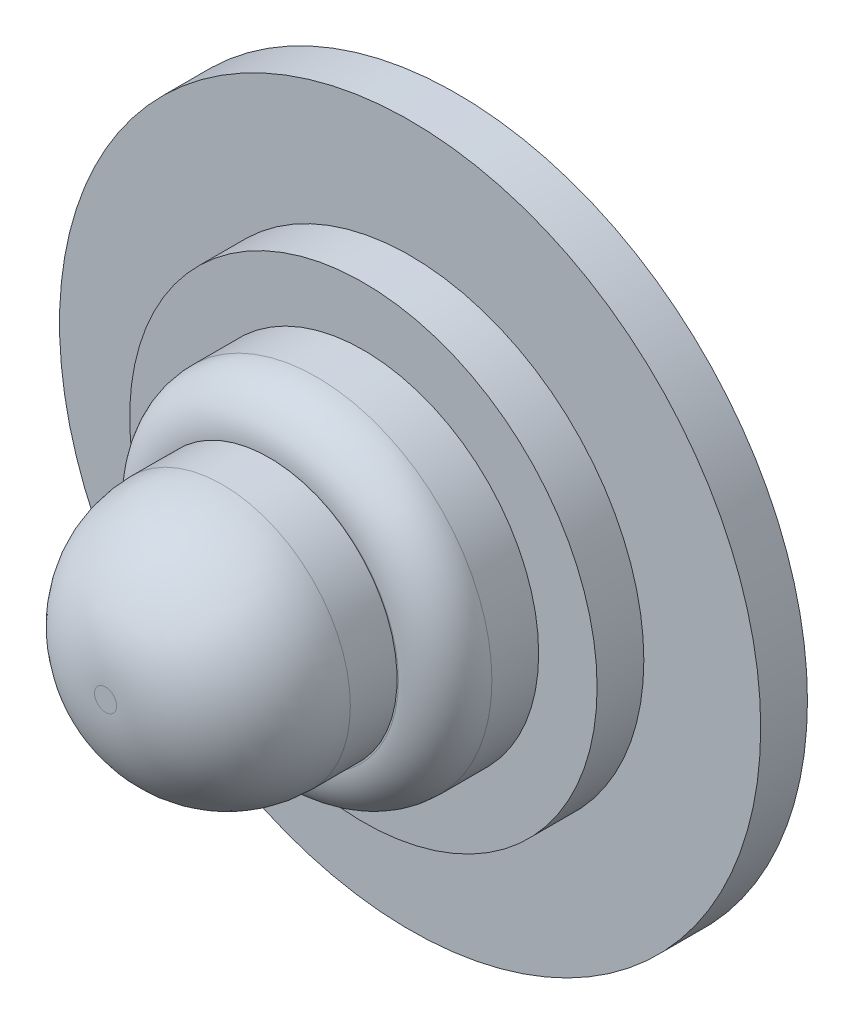
from build123d import *

# Parameters (mm, degrees)
SKETCH1_R           = 15
BOSS_EXTRUDE1_DEPTH = 2
SKETCH2_R           = 10
BOSS_EXTRUDE2_DEPTH = 2
SKETCH3_R           = 7.5
BOSS_EXTRUDE3_DEPTH = 4
FILLET1_R           = 2
SKETCH4_R           = 5.471529996
BOSS_EXTRUDE4_DEPTH = 7
FILLET2_R           = 5


with BuildPart() as part:
    # Sketch1 → Boss-Extrude1 (new body)
    with BuildSketch(Plane.XY):
        with Locations((-7.532732603, 13.127432061)):
            Circle(SKETCH1_R)
    extrude(amount=BOSS_EXTRUDE1_DEPTH)

    # Sketch2 → Boss-Extrude2 (add)
    with BuildSketch(Plane.XY.offset(2)):
        with Locations((-7.532732603, 13.127432061)):
            Circle(SKETCH2_R)
    extrude(amount=BOSS_EXTRUDE2_DEPTH)

    # Sketch3 → Boss-Extrude3 (add)
    with BuildSketch(Plane.XY.offset(4)):
        with Locations((-7.532732603, 13.127432061)):
            Circle(SKETCH3_R)
    extrude(amount=BOSS_EXTRUDE3_DEPTH)

    # Fillet1
    fillet1_edges = [part.edges().sort_by_distance(p)[0] for p in [
        (-15.032732603, 13.127432061, 8),
    ]]
    fillet(fillet1_edges, radius=FILLET1_R)

    # Sketch4 → Boss-Extrude4 (add)
    with BuildSketch(Plane.XY.offset(8)):
        with Locations((-7.561660228, 13.153988569)):
            Circle(SKETCH4_R)
    extrude(amount=BOSS_EXTRUDE4_DEPTH)

    # Fillet2
    fillet2_edges = [part.edges().sort_by_distance(p)[0] for p in [
        (-13.033190224, 13.153988569, 15),
    ]]
    fillet(fillet2_edges, radius=FILLET2_R)


solid = part.part
